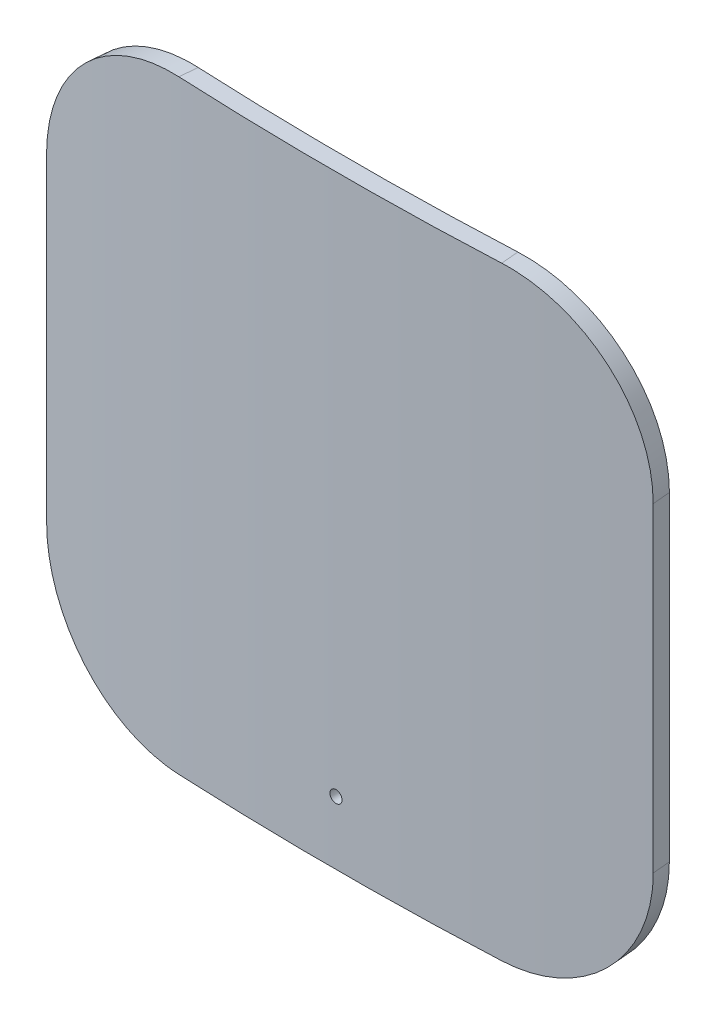
from build123d import *

# Parameters (mm, degrees)
LINEAR_AUSTRAGEN_D_NN1_DEPTH      = 170
LINEAR_AUSTRAGEN_D_NN1_DEPTH_BACK = 170
VERRUNDUNG1_R                     = 80
F_6_8_6_8_DURCHMESSER_BOHRUNG1_D  = 6.8


with BuildPart() as part:
    # Skizze2 → Linear-Austragen-Dünn1 (new body, two sides)
    with BuildSketch(Plane(origin=(0, 0, 0), x_dir=(1, 0, 0), z_dir=(0, 1, 0))) as linear_austragen_d_nn1_sk:
        with BuildLine():
            ThreePointArc((-169.777732917, -2.47495966), (0, -10), (169.777732917, -2.47495966))
            Line((169.777732917, -2.47495966), (170.662452734, -12.435746318))
            ThreePointArc((170.662452734, -12.435746318), (0, -20), (-170.662452734, -12.435746318))
            Line((-170.662452734, -12.435746318), (-169.777732917, -2.47495966))
        make_face()
    extrude(amount=LINEAR_AUSTRAGEN_D_NN1_DEPTH)
    extrude(linear_austragen_d_nn1_sk.sketch, amount=-LINEAR_AUSTRAGEN_D_NN1_DEPTH_BACK)

    # Verrundung1
    verrundung1_edges = [part.edges().sort_by_distance(p)[0] for p in [
        (170.220092826, 170, 7.455352989),
        (-170.220092826, 170, 7.455352989),
        (-170.220092826, -170, 7.455352989),
        (170.220092826, -170, 7.455352989),
    ]]
    fillet(verrundung1_edges, radius=VERRUNDUNG1_R)

    # Ø6.8 (6.8) Durchmesser Bohrung1 (through all)
    with Locations(Plane(origin=(-0.304533865, -134.419932379, 19.999975961), x_dir=(0.999999988, 0, 0.000157871), z_dir=(-0.000157871, 0, 0.999999988))):
        with Locations((0, 0)):
            Hole(F_6_8_6_8_DURCHMESSER_BOHRUNG1_D / 2)


solid = part.part
